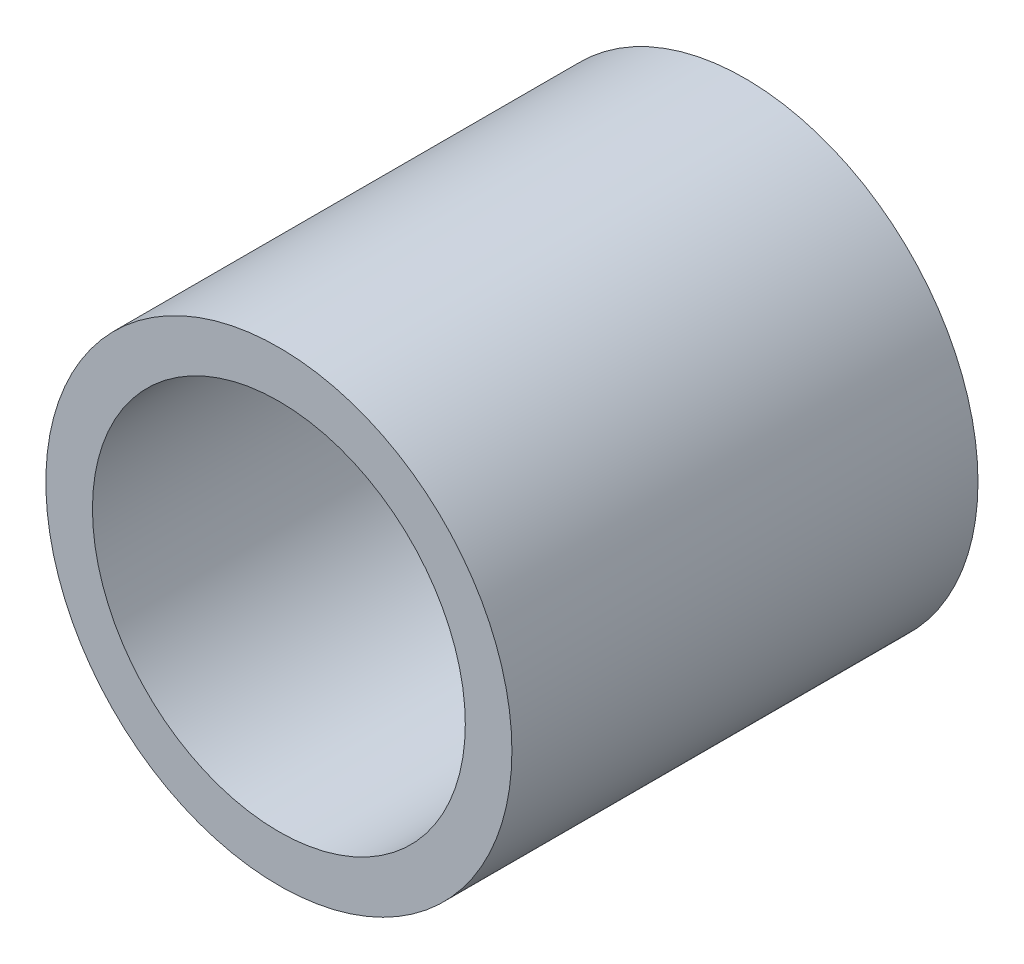
from build123d import *

# Parameters (mm, degrees)
SKETCH_1_R          = 2
SKETCH_1_R_2        = 1
EXTRUDE_1_DEPTH     = 1.6
SKETCH_2_R          = 2.5
EXTRUDE_2_DEPTH     = 5
SKETCH_3_R          = 2
CUT_EXTRUDE_1_DEPTH = 3.4
SKETCH_4_R          = 1
CUT_EXTRUDE_2_DEPTH = 3.4


with BuildPart() as part:
    # 草图1 → 凸台-拉伸1 (new body)
    with BuildSketch(Plane.XY):
        Circle(SKETCH_1_R)
        Circle(SKETCH_1_R_2, mode=Mode.SUBTRACT)
    extrude(amount=EXTRUDE_1_DEPTH)

    # 草图2 → 凸台-拉伸2 (add)
    with BuildSketch(Plane.XY):
        Circle(SKETCH_2_R)
    extrude(amount=EXTRUDE_2_DEPTH)

    # 草图3 → 切除-拉伸1 (cut)
    with BuildSketch(Plane.XY.offset(5)):
        Circle(SKETCH_3_R)
    extrude(amount=-CUT_EXTRUDE_1_DEPTH, mode=Mode.SUBTRACT)

    # 草图4 → 切除-拉伸2 (cut)
    with BuildSketch(Plane.XY.offset(1.6)):
        Circle(SKETCH_4_R)
    extrude(amount=-CUT_EXTRUDE_2_DEPTH, mode=Mode.SUBTRACT)


solid = part.part
